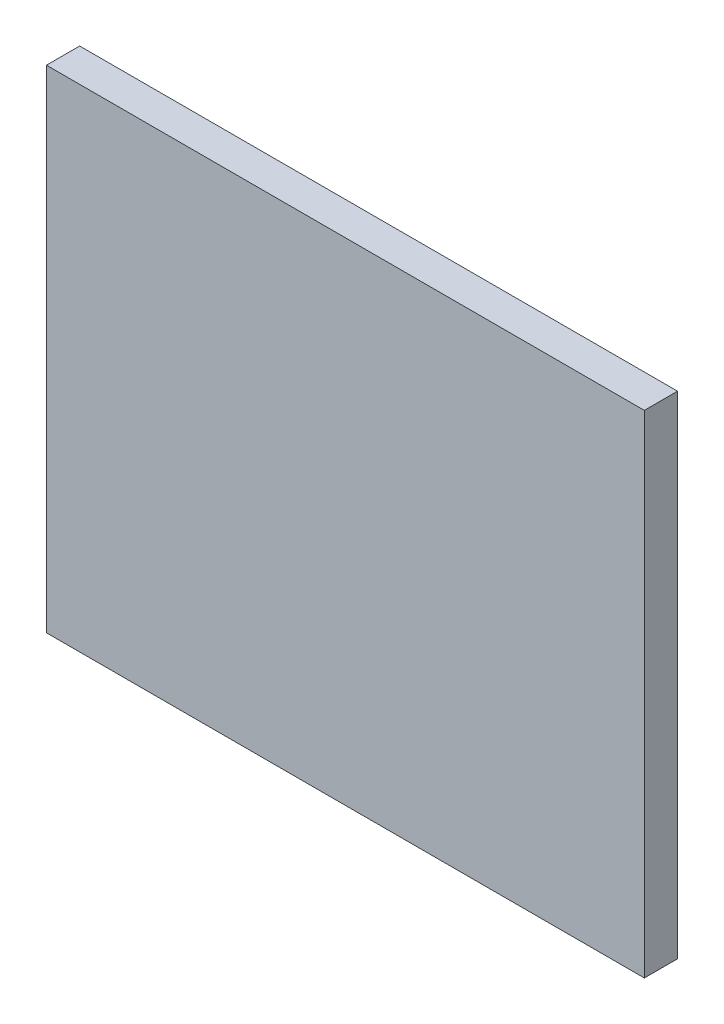
from build123d import *

# Parameters (mm, degrees)
CROQUIS1_W              = 90
CROQUIS1_H              = 74
SALIENTE_EXTRUIR1_DEPTH = 5
CROQUIS3_W              = 30
CROQUIS3_H              = 25
SALIENTE_EXTRUIR2_DEPTH = 1


with BuildPart() as part:
    # Croquis1 → Saliente-Extruir1 (new body)
    with BuildSketch(Plane.XY):
        Rectangle(CROQUIS1_W, CROQUIS1_H)
    extrude(amount=SALIENTE_EXTRUIR1_DEPTH)

    # Croquis3 → Saliente-Extruir2 (add)
    with BuildSketch(Plane(origin=(0, 0, 0), x_dir=(-1, 0, 0), z_dir=(0, 0, -1))):
        with Locations((-25, 20)):
            Rectangle(CROQUIS3_W, CROQUIS3_H)
        with Locations((-25, -20)):
            Rectangle(CROQUIS3_W, CROQUIS3_H)
        with Locations((25, 20)):
            Rectangle(CROQUIS3_W, CROQUIS3_H)
        with Locations((25, -20)):
            Rectangle(CROQUIS3_W, CROQUIS3_H)
    extrude(amount=SALIENTE_EXTRUIR2_DEPTH)


solid = part.part
